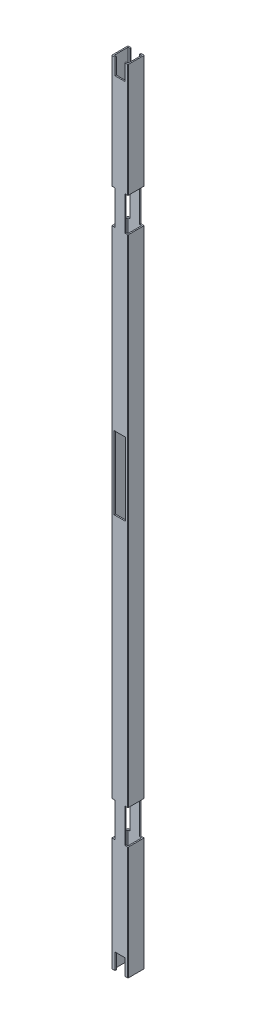
from build123d import *

# Parameters (mm, degrees)
SKETCH1_W           = 17
SKETCH1_H           = 17
BOSS_EXTRUDE1_DEPTH = 977
SKETCH2_W           = 12
SKETCH2_H           = 20
CUT_EXTRUDE1_DEPTH  = 1177
SKETCH3_W           = 4
SKETCH3_H           = 42.2
CUT_EXTRUDE2_DEPTH  = 1177
SKETCH7_W           = 14
SKETCH7_H           = 90
CUT_EXTRUDE5_DEPTH  = 10
SKETCH8_R           = 2.5
CUT_EXTRUDE6_DEPTH  = 10


with BuildPart() as part:
    # Sketch1 → Boss-Extrude1 (new body)
    with BuildSketch(Plane(origin=(0, 0, 0), x_dir=(1, 0, 0), z_dir=(0, 1, 0))):
        with BuildLine():
            Line((0.5, 0), (19.5, 0))
            ThreePointArc((19.5, 0), (19.853553391, 0.146446609), (20, 0.5))
            Line((20, 0.5), (20, 19.5))
            ThreePointArc((20, 19.5), (19.853553391, 19.853553391), (19.5, 20))
            Line((19.5, 20), (0.5, 20))
            ThreePointArc((0.5, 20), (0.146446609, 19.853553391), (0, 19.5))
            Line((0, 19.5), (0, 0.5))
            ThreePointArc((0, 0.5), (0.146446609, 0.146446609), (0.5, 0))
        make_face()
        with Locations((10, 10)):
            Rectangle(SKETCH1_W, SKETCH1_H, mode=Mode.SUBTRACT)
    extrude(amount=BOSS_EXTRUDE1_DEPTH)

    # Sketch2 → Cut-Extrude1 (cut)
    with BuildSketch(Plane.XY):
        with Locations((10, 967)):
            Rectangle(SKETCH2_W, SKETCH2_H)
    cut_extrude1 = extrude(amount=-CUT_EXTRUDE1_DEPTH, mode=Mode.SUBTRACT)

    # Sketch3 → Cut-Extrude2 (cut)
    with BuildSketch(Plane(origin=(0, 0, -20), x_dir=(-1, 0, 0), z_dir=(0, 0, -1))):
        with Locations((-2, 815.9)):
            Rectangle(SKETCH3_W, SKETCH3_H)
        with Locations((-18, 815.9)):
            Rectangle(SKETCH3_W, SKETCH3_H)
    cut_extrude2 = extrude(amount=-CUT_EXTRUDE2_DEPTH, mode=Mode.SUBTRACT)

    # Mirror1: Cut-Extrude1, Cut-Extrude2 across plane
    add(cut_extrude1.mirror(Plane.ZX.offset(488.5)), mode=Mode.SUBTRACT)
    add(cut_extrude2.mirror(Plane.ZX.offset(488.5)), mode=Mode.SUBTRACT)

    # Sketch7 → Cut-Extrude5 (cut)
    with BuildSketch(Plane.XY):
        with Locations((10, 532)):
            Rectangle(SKETCH7_W, SKETCH7_H)
    extrude(amount=-CUT_EXTRUDE5_DEPTH, mode=Mode.SUBTRACT)

    # Sketch8 → Cut-Extrude6 (cut)
    with BuildSketch(Plane.XY.offset(-18.5)):
        with Locations((10, 567)):
            Circle(SKETCH8_R)
        with Locations((10, 497)):
            Circle(SKETCH8_R)
    extrude(amount=-CUT_EXTRUDE6_DEPTH, mode=Mode.SUBTRACT)


solid = part.part
